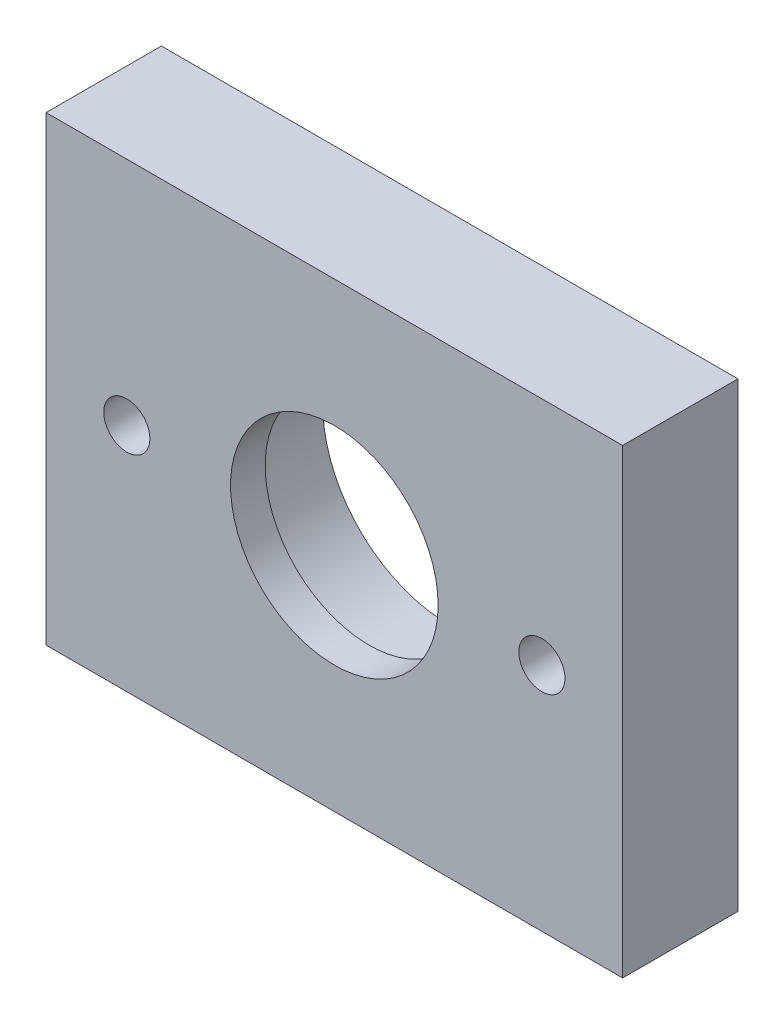
from build123d import *

# Parameters (mm, degrees)
SKETCH1_W           = 50
SKETCH1_H           = 40
SKETCH1_R           = 11
SKETCH1_R_2         = 2
BOSS_EXTRUDE1_DEPTH = 10
SKETCH2_R           = 11
SKETCH2_R_2         = 9
BOSS_EXTRUDE2_DEPTH = 3


with BuildPart() as part:
    # Sketch1 → Boss-Extrude1 (new body)
    with BuildSketch(Plane.XY):
        Rectangle(SKETCH1_W, SKETCH1_H)
        Circle(SKETCH1_R, mode=Mode.SUBTRACT)
        with Locations((-18, 0)):
            Circle(SKETCH1_R_2, mode=Mode.SUBTRACT)
        with Locations((18, 0)):
            Circle(SKETCH1_R_2, mode=Mode.SUBTRACT)
    extrude(amount=BOSS_EXTRUDE1_DEPTH)

    # Sketch2 → Boss-Extrude2 (add)
    with BuildSketch(Plane.XY.offset(10)):
        Circle(SKETCH2_R)
        Circle(SKETCH2_R_2, mode=Mode.SUBTRACT)
    extrude(amount=-BOSS_EXTRUDE2_DEPTH)


solid = part.part
